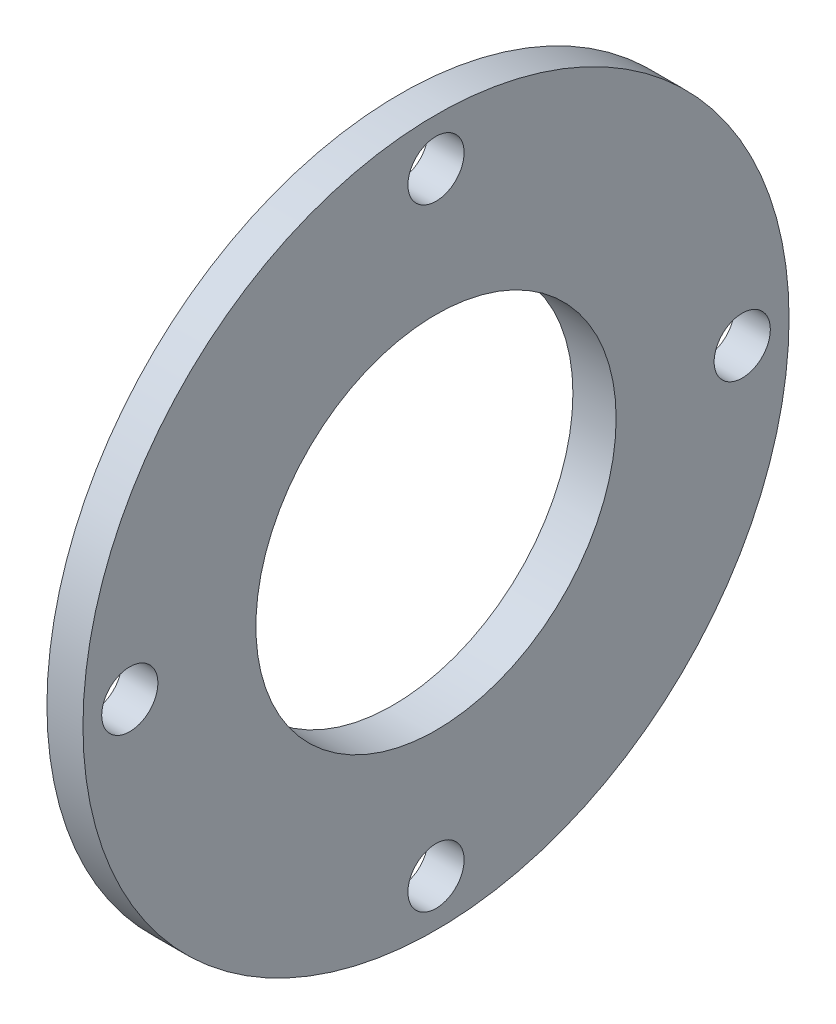
from build123d import *

# Parameters (mm, degrees)
SKETCH3_R          = 3.9
CUT_EXTRUDE1_DEPTH = 10
CIRPATTERN1_COUNT  = 4


with BuildPart() as part:
    # Sketch1 → Revolve1 (revolve)
    with BuildSketch(Plane.XY):
        Polygon((0, 31), (0, 36), (3, 36), (3, 49), (8, 49), (8, 25), (2, 25), (2, 31), align=None)
    revolve(axis=Axis((0, 0, 0), (-1, 0, 0)))

    # Sketch3 → Cut-Extrude1 (cut)
    with BuildSketch(Plane.ZY.offset(-3)):
        with Locations((42.5, 0)):
            Circle(SKETCH3_R)
    cut_extrude1 = extrude(amount=-CUT_EXTRUDE1_DEPTH, mode=Mode.SUBTRACT)

    # CirPattern1: Cut-Extrude1 ×4 about axis
    cirpattern1_axis = Axis((0, 0, 0), (1, 0, 0))
    for i in range(1, CIRPATTERN1_COUNT):
        add(cut_extrude1.rotate(cirpattern1_axis, i * 360 / CIRPATTERN1_COUNT), mode=Mode.SUBTRACT)


solid = part.part
